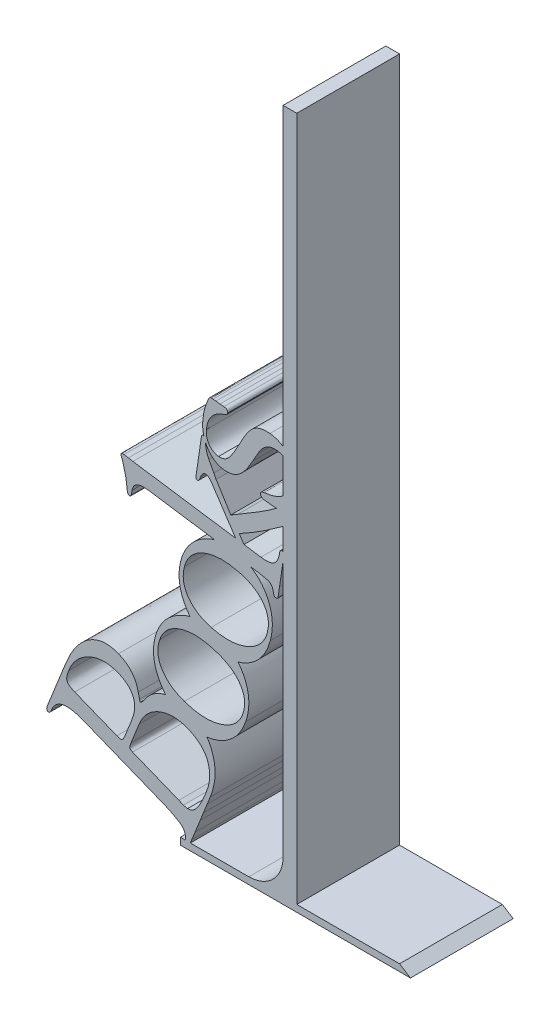
from build123d import *

# Parameters (mm, degrees)
BOSS_EXTRU_1_DEPTH = 30
BOSS_EXTRU_2_DEPTH = 30
CONG_1_R           = 10


with BuildPart() as part:
    # Esquisse1 → Boss.-Extru.1 (new body)
    with BuildSketch(Plane.XY):
        Polygon((0, 0), (37.189024069, 0), (34, 2), (4, 2), (4, 202), (0, 202), (0, 2), (-30, 2), (-30, 0), align=None)
    extrude(amount=BOSS_EXTRU_1_DEPTH)

    # Esquisse3 → Boss.-Extru.2 (add)
    with BuildSketch(Plane.XY):
        with BuildLine():
            Line((-35.302112501, 8.159006031), (-58.03965473, 17.252122586))
            add(Edge.make_bspline(
                [(-58.03965473, 17.252122586), (-58.355313773, 17.375350481), (-58.963035361, 17.612594602), (-59.859878294, 17.909773183), (-60.707648298, 18.138306557), (-61.506749373, 18.309469684), (-62.257632658, 18.432846565), (-62.964456405, 18.466854455), (-63.619206387, 18.451012021), (-64.229039011, 18.378327095), (-64.789443117, 18.233792106), (-65.314670395, 18.03619935), (-65.788879376, 17.757851222), (-66.220300759, 17.416496), (-66.629128968, 17.029218094), (-66.972831335, 16.555351762), (-67.295412383, 16.032333184), (-67.457774308, 15.6457702), (-67.541343919, 15.44680164)],
                knots=[0, 0, 0, 0, 0.001016459, 0.001956934, 0.002832792, 0.003649053, 0.004408297, 0.005112448, 0.00576834, 0.006371753, 0.006950187, 0.007500711, 0.008049922, 0.008591602, 0.009149295, 0.009732702, 0.010342145, 0.010988539, 0.010988539, 0.010988539, 0.010988539], degree=3))
            add(Edge.make_bspline(
                [(-67.541343919, 15.44680164), (-67.619917515, 15.265028843), (-67.75613238, 14.94990826), (-68.016939385, 14.588639119), (-68.325098744, 14.368209351), (-68.533711269, 14.416431409), (-68.634038176, 14.439622586)],
                knots=[0, 0, 0, 0, 0.000590712, 0.001024055, 0.001343459, 0.001639388, 0.001639388, 0.001639388, 0.001639388], degree=3))
            add(Edge.make_bspline(
                [(-68.634038176, 14.439622586), (-68.723149832, 14.491482144), (-68.908289689, 14.599226424), (-69.002186568, 14.957038171), (-68.955219486, 15.384166665), (-68.847878543, 15.68921238), (-68.786065203, 15.864875964)],
                knots=[0, 0, 0, 0, 0.000298359, 0.000619876, 0.001029442, 0.001585514, 0.001585514, 0.001585514, 0.001585514], degree=3))
            add(Edge.make_bspline(
                [(-68.786065203, 15.864875964), (-68.760613163, 15.925005499), (-68.692518061, 16.085877739), (-68.568086622, 16.392771783), (-68.399242924, 16.831966319), (-68.264070327, 17.166843433), (-68.187458784, 17.356641167)],
                knots=[0, 0, 0, 0, 0.000195882, 0.000524069, 0.000993418, 0.001607436, 0.001607436, 0.001607436, 0.001607436], degree=3))
            add(Edge.make_bspline(
                [(-68.187458784, 17.356641167), (-68.124265359, 17.518228579), (-67.986526828, 17.870429981), (-67.760475296, 18.438196242), (-67.490100792, 19.084427522), (-67.306262609, 19.544909176), (-67.208784798, 19.789073599)],
                knots=[0, 0, 0, 0, 0.000520516, 0.001134534, 0.001833279, 0.002621977, 0.002621977, 0.002621977, 0.002621977], degree=3))
            add(Edge.make_bspline(
                [(-67.208784798, 19.789073599), (-67.072882739, 20.131249445), (-66.817360969, 20.774605244), (-66.455736839, 21.672615505), (-66.15185427, 22.446745686), (-65.964214431, 22.918356439), (-65.878548311, 23.133668194)],
                knots=[0, 0, 0, 0, 0.001104528, 0.002076723, 0.002904243, 0.003599427, 0.003599427, 0.003599427, 0.003599427], degree=3))
            Line((-65.878548311, 23.133668194), (-64.557813514, 26.421252653))
            add(Edge.make_bspline(
                [(-64.557813514, 26.421252653), (-64.358699535, 26.925009982), (-63.971498429, 27.904626757), (-63.579515629, 28.882339884), (-63.389105744, 29.357274613)],
                knots=[0, 0, 0, 0, 0.001625039, 0.003160084, 0.003160084, 0.003160084, 0.003160084], degree=3))
            add(Edge.make_bspline(
                [(-63.389105744, 29.357274613), (-63.169378716, 29.878990693), (-62.741252187, 30.895526972), (-62.028419496, 32.346047181), (-61.264446433, 33.675917014), (-60.441002755, 34.877622829), (-59.585828991, 35.967872333), (-58.684009334, 36.945364246), (-57.721967137, 37.790435082), (-56.721217306, 38.518352039), (-55.690794802, 39.11682277), (-54.639763368, 39.579989604), (-53.573012969, 39.895018553), (-52.492016618, 40.084112375), (-51.392028033, 40.105988696), (-50.280501147, 39.997525603), (-49.149644692, 39.767640647), (-48.417659495, 39.493194928), (-48.043877703, 39.35305164)],
                knots=[0, 0, 0, 0, 0.00169804, 0.003308541, 0.004845379, 0.006294877, 0.007674946, 0.008999367, 0.010278465, 0.011510062, 0.012706294, 0.013846655, 0.014946965, 0.016035728, 0.017128794, 0.018235934, 0.019382021, 0.020577951, 0.020577951, 0.020577951, 0.020577951], degree=3))
            add(Edge.make_bspline(
                [(-48.043877703, 39.35305164), (-47.666245753, 39.186840964), (-46.929447075, 38.862546884), (-45.909438878, 38.25032833), (-45.015153381, 37.531646077), (-44.220025728, 36.731039995), (-43.565319734, 35.813141879), (-43.010001062, 34.814973298), (-42.576846349, 33.714468443), (-42.384625837, 32.938875825), (-42.285854055, 32.540340491)],
                knots=[0, 0, 0, 0, 0.001237009, 0.002413531, 0.003556147, 0.004671533, 0.005787163, 0.00692693, 0.008091459, 0.009322322, 0.009322322, 0.009322322, 0.009322322], degree=3))
            Line((-42.285854055, 32.540340491), (-41.896284798, 30.925053329))
            add(Edge.make_bspline(
                [(-41.896284798, 30.925053329), (-41.878934045, 30.771008605), (-41.852359302, 30.535070784), (-41.68041649, 30.380201451), (-41.620735811, 30.32644691)],
                knots=[0, 0, 0, 0, 0.000442518, 0.000677768, 0.000677768, 0.000677768, 0.000677768], degree=3))
            add(Edge.make_bspline(
                [(-41.620735811, 30.32644691), (-41.551563248, 30.340392893), (-41.363504833, 30.378307631), (-41.107817162, 30.675592142), (-40.755065825, 31.091008245), (-40.514510479, 31.456029721), (-40.376014528, 31.666185086)],
                knots=[0, 0, 0, 0, 0.00020752, 0.000564182, 0.001117731, 0.001868906, 0.001868906, 0.001868906, 0.001868906], degree=3))
            add(Edge.make_bspline(
                [(-40.376014528, 31.666185086), (-40.203849696, 31.914146666), (-39.862595765, 32.405639982), (-39.263951712, 33.06496259), (-38.640302078, 33.68092014), (-37.9581207, 34.222028113), (-37.235380288, 34.714050807), (-36.453003414, 35.124879102), (-35.63389224, 35.492566677), (-34.770383596, 35.782245849), (-33.88471145, 36.010300137), (-32.99157699, 36.162220932), (-32.10165262, 36.240058743), (-31.214937057, 36.238636955), (-30.326604735, 36.166750555), (-29.442944458, 35.995665553), (-28.554461563, 35.778161822), (-27.980664066, 35.558598107), (-27.69125946, 35.447857383)],
                knots=[0, 0, 0, 0, 0.000904659, 0.001793155, 0.002666691, 0.003531814, 0.004401466, 0.005285684, 0.006179045, 0.007092493, 0.008014304, 0.008920309, 0.009807229, 0.010690887, 0.011577807, 0.012476106, 0.013388714, 0.014317403, 0.014317403, 0.014317403, 0.014317403], degree=3))
            add(Edge.make_bspline(
                [(-27.69125946, 35.447857383), (-27.265753786, 35.263404732), (-26.432274912, 34.902099591), (-25.272392763, 34.218936166), (-24.223954607, 33.435580334), (-23.26953076, 32.559703627), (-22.444950765, 31.561451076), (-21.716105466, 30.470897878), (-21.097465064, 29.279335813), (-20.600921226, 27.996516562), (-20.206775025, 26.656863977), (-19.966413692, 25.273077575), (-19.838716302, 23.868225734), (-19.847625921, 22.439163094), (-20.004316595, 20.985994781), (-20.296902681, 19.510988717), (-20.696421705, 18.002929073), (-21.075117354, 17.014657935), (-21.268117568, 16.510990829)],
                knots=[0, 0, 0, 0, 0.001390302, 0.002723318, 0.004026956, 0.00531109, 0.006599437, 0.007901272, 0.009239966, 0.010618005, 0.01202236, 0.013422079, 0.014824278, 0.016249563, 0.017701799, 0.019201893, 0.020757764, 0.022374839, 0.022374839, 0.022374839, 0.022374839], degree=3))
            Line((-21.268117568, 16.510990829), (-22.170778041, 14.240087113))
            Line((-22.170778041, 14.240087113), (-23.263472298, 11.503600626))
            Line((-23.263472298, 11.503600626), (-24.213641217, 9.128178329))
            add(Edge.make_bspline(
                [(-24.213641217, 9.128178329), (-24.361571263, 8.754073749), (-24.640130174, 8.049618053), (-25.047724429, 7.059767976), (-25.382308567, 6.183283802), (-25.603129942, 5.643857322), (-25.705406419, 5.394014477)],
                knots=[0, 0, 0, 0, 0.001206864, 0.002272579, 0.003211277, 0.004021153, 0.004021153, 0.004021153, 0.004021153], degree=3))
            add(Edge.make_bspline(
                [(-25.705406419, 5.394014477), (-25.87572996, 4.966153219), (-26.188971304, 4.179275285), (-26.50938508, 3.395291682), (-26.655575338, 3.037595558)],
                knots=[0, 0, 0, 0, 0.00138154, 0.002540785, 0.002540785, 0.002540785, 0.002540785], degree=3))
            add(Edge.make_bspline(
                [(-26.655575338, 3.037595558), (-26.740201249, 2.818702199), (-26.895028946, 2.418224918), (-27.121148607, 1.870154371), (-27.294048616, 1.420492239), (-27.405677567, 1.156045727), (-27.45371723, 1.042240829)],
                knots=[0, 0, 0, 0, 0.000704023, 0.001288049, 0.00177856, 0.002149126, 0.002149126, 0.002149126, 0.002149126], degree=3))
            add(Edge.make_bspline(
                [(-27.45371723, 1.042240829), (-27.507364885, 0.924746659), (-27.603880451, 0.713367125), (-27.823201528, 0.469730152), (-28.11516529, 0.376212114), (-28.296807436, 0.432435134), (-28.39438446, 0.462637788)],
                knots=[0, 0, 0, 0, 0.000386778, 0.000695839, 0.000954313, 0.001254332, 0.001254332, 0.001254332, 0.001254332], degree=3))
            add(Edge.make_bspline(
                [(-28.39438446, 0.462637788), (-28.467866027, 0.50356667), (-28.616519866, 0.586366149), (-28.720753854, 0.856663082), (-28.728652929, 1.190573434), (-28.679045201, 1.435515017), (-28.650930068, 1.574335423)],
                knots=[0, 0, 0, 0, 0.00024521, 0.000496062, 0.000819678, 0.00124301, 0.00124301, 0.00124301, 0.00124301], degree=3))
            add(Edge.make_bspline(
                [(-28.650930068, 1.574335423), (-28.607401578, 1.785657401), (-28.523538759, 2.192794356), (-28.49102629, 2.798668844), (-28.560368307, 3.369166081), (-28.70927724, 3.904079452), (-28.955410011, 4.401962582), (-29.28917227, 4.86186631), (-29.728172918, 5.27280665), (-30.063581904, 5.508957239), (-30.237712163, 5.631556707)],
                knots=[0, 0, 0, 0, 0.000646743, 0.001246028, 0.00181056, 0.002363946, 0.002903622, 0.003468074, 0.004059473, 0.004697998, 0.004697998, 0.004697998, 0.004697998], degree=3))
            add(Edge.make_bspline(
                [(-30.237712163, 5.631556707), (-30.583806243, 5.847678046), (-31.310995358, 6.301777361), (-32.504529353, 6.935388369), (-33.848046102, 7.561448849), (-34.803139698, 7.953950209), (-35.302112501, 8.159006031)],
                knots=[0, 0, 0, 0, 0.001223801, 0.002571367, 0.004050613, 0.005668832, 0.005668832, 0.005668832, 0.005668832], degree=3))
        make_face()
        with BuildLine():
            Line((-46.08652973, 19.694056707), (-44.186191892, 24.46390468))
            add(Edge.make_bspline(
                [(-44.186191892, 24.46390468), (-44.074721727, 24.760299336), (-43.859855049, 25.331621134), (-43.607548383, 26.187951087), (-43.437838458, 27.008059297), (-43.338011243, 27.796234646), (-43.319121678, 28.547173716), (-43.369504847, 29.266044629), (-43.520987168, 29.945201824), (-43.72158397, 30.59851231), (-44.027453098, 31.207172772), (-44.384515049, 31.795526321), (-44.838153609, 32.336327745), (-45.363534479, 32.84305256), (-45.96950405, 33.308256836), (-46.644783221, 33.746099555), (-47.398251889, 34.146912862), (-47.937362645, 34.37220281), (-48.214908109, 34.488186775)],
                knots=[0, 0, 0, 0, 0.000949789, 0.001830785, 0.00267494, 0.003459851, 0.004210725, 0.004925628, 0.005615139, 0.006294228, 0.006969917, 0.007652784, 0.008354752, 0.009080497, 0.009838849, 0.010642683, 0.011492805, 0.012394865, 0.012394865, 0.012394865, 0.012394865], degree=3))
            add(Edge.make_bspline(
                [(-48.214908109, 34.488186775), (-48.567259133, 34.619193315), (-49.261897009, 34.877464468), (-50.330337719, 35.130390391), (-51.39317254, 35.276847634), (-52.454384403, 35.306042355), (-53.510750766, 35.216548571), (-54.566888728, 35.029615034), (-55.613187603, 34.710873197), (-56.642017048, 34.283615555), (-57.636252595, 33.765267104), (-58.567989569, 33.156511669), (-59.427432723, 32.469616665), (-60.216560502, 31.701998545), (-60.926170434, 30.846010762), (-61.564464841, 29.91040188), (-62.131360198, 28.895935837), (-62.442048422, 28.175727169), (-62.600465541, 27.808499275)],
                knots=[0, 0, 0, 0, 0.001126862, 0.002221537, 0.003285811, 0.004340884, 0.005399033, 0.006461354, 0.00755256, 0.008673034, 0.009799295, 0.010911439, 0.012006568, 0.013095082, 0.01420824, 0.015336223, 0.016488908, 0.017688117, 0.017688117, 0.017688117, 0.017688117], degree=3))
            add(Edge.make_bspline(
                [(-62.600465541, 27.808499275), (-62.7156248, 27.50043675), (-62.925312334, 26.939501647), (-63.109527137, 26.144585285), (-63.181187993, 25.484877529), (-63.082277344, 24.92262247), (-62.773817218, 24.451957203), (-62.287947379, 24.040006067), (-61.616910769, 23.641589613), (-61.09301385, 23.418172151), (-60.804646284, 23.29519691)],
                knots=[0, 0, 0, 0, 0.000985614, 0.001794654, 0.002442513, 0.002966141, 0.003469731, 0.004095473, 0.004862996, 0.005802703, 0.005802703, 0.005802703, 0.005802703], degree=3))
            Line((-60.804646284, 23.29519691), (-48.499958784, 18.37332191))
            add(Edge.make_bspline(
                [(-48.499958784, 18.37332191), (-48.336482077, 18.312986371), (-48.038955366, 18.203176021), (-47.624145983, 18.1003381), (-47.287944665, 18.082734748), (-46.999145372, 18.144668154), (-46.775836505, 18.368955121), (-46.548732279, 18.687558707), (-46.32176643, 19.149220841), (-46.170205247, 19.500254368), (-46.08652973, 19.694056707)],
                knots=[0, 0, 0, 0, 0.000522852, 0.000951588, 0.001274785, 0.001530626, 0.001806829, 0.00219454, 0.002708774, 0.003342615, 0.003342615, 0.003342615, 0.003342615], degree=3))
        make_face(mode=Mode.SUBTRACT)
        with BuildLine():
            add(Edge.make_bspline(
                [(-44.385727365, 18.648870896), (-44.453678344, 18.485652257), (-44.576078147, 18.19164723), (-44.679711168, 17.779600312), (-44.765451733, 17.465471787), (-44.762296774, 17.213044883), (-44.677882888, 17.005318803), (-44.494776099, 16.843127027), (-44.248484023, 16.683341967), (-44.048581726, 16.59652457), (-43.939147974, 16.548997586)],
                knots=[0, 0, 0, 0, 0.000529373, 0.000953557, 0.001274089, 0.001502328, 0.00169821, 0.001926646, 0.002221811, 0.002578852, 0.002578852, 0.002578852, 0.002578852], degree=3))
            Line((-43.939147974, 16.548997586), (-30.418244257, 11.142536437))
            Line((-30.418244257, 11.142536437), (-29.09750946, 10.543930018))
            Line((-29.09750946, 10.543930018), (-27.881293244, 10.277882721))
            add(Edge.make_bspline(
                [(-27.881293244, 10.277882721), (-27.644083423, 10.281839645), (-27.163021767, 10.289864289), (-26.467907739, 10.591656717), (-25.79766613, 11.057543304), (-25.163204681, 11.758943031), (-24.525465815, 12.682456471), (-23.868148397, 13.856062501), (-23.185486694, 15.294230022), (-22.748392778, 16.350389448), (-22.512838852, 16.919563464)],
                knots=[0, 0, 0, 0, 0.000705432, 0.001430617, 0.002229268, 0.003143408, 0.004247976, 0.005592692, 0.007173632, 0.009021386, 0.009021386, 0.009021386, 0.009021386], degree=3))
            add(Edge.make_bspline(
                [(-22.512838852, 16.919563464), (-22.368016386, 17.304095456), (-22.08499336, 18.05557698), (-21.763441588, 19.183132479), (-21.538927387, 20.275360058), (-21.422258329, 21.331701702), (-21.414605082, 22.356204778), (-21.494311668, 23.344232539), (-21.687823017, 24.297057692), (-21.981714929, 25.208452101), (-22.373559285, 26.073380396), (-22.848317416, 26.89278835), (-23.435120186, 27.64144354), (-24.103897269, 28.341888886), (-24.86621338, 28.978348844), (-25.725546186, 29.552110635), (-26.672529698, 30.074920077), (-27.352795548, 30.367051394), (-27.700761149, 30.516480694)],
                knots=[0, 0, 0, 0, 0.001232293, 0.002408239, 0.003513258, 0.00457409, 0.005590816, 0.006582685, 0.007542355, 0.008500896, 0.009449258, 0.010386271, 0.011334633, 0.01229562, 0.013287125, 0.014306997, 0.015391398, 0.016526919, 0.016526919, 0.016526919, 0.016526919], degree=3))
            add(Edge.make_bspline(
                [(-27.700761149, 30.516480694), (-28.06597229, 30.65293199), (-28.786848191, 30.922267835), (-29.888034936, 31.20588688), (-30.976368869, 31.376916338), (-32.052021312, 31.449181938), (-33.115247274, 31.397658109), (-34.170262123, 31.248393276), (-35.209213129, 30.9759614), (-36.228881151, 30.610834367), (-37.202209186, 30.143075928), (-38.124605827, 29.606156758), (-38.958844486, 28.96279075), (-39.728237346, 28.24835251), (-40.410452445, 27.441769124), (-41.037197262, 26.563747679), (-41.576102259, 25.590893885), (-41.876560756, 24.900436159), (-42.029308446, 24.549419883)],
                knots=[0, 0, 0, 0, 0.001169017, 0.002307476, 0.003404088, 0.004470354, 0.005535603, 0.006591787, 0.007661097, 0.008752137, 0.009835913, 0.010896746, 0.01194766, 0.012989602, 0.014040817, 0.015111139, 0.016221374, 0.017369467, 0.017369467, 0.017369467, 0.017369467], degree=3))
            Line((-42.029308446, 24.549419883), (-44.385727365, 18.648870896))
        make_face(mode=Mode.SUBTRACT)
        with BuildLine():
            add(Edge.make_bspline(
                [(-36.972241579, 50.116979393), (-36.807837935, 50.561482078), (-36.483566384, 51.438224052), (-35.832902584, 52.665210126), (-35.104203056, 53.810374036), (-34.271076676, 54.868403768), (-33.324576665, 55.825492512), (-32.286342593, 56.70700323), (-31.138998894, 57.488615003), (-29.90006691, 58.162704485), (-28.616235713, 58.739969798), (-27.308803719, 59.182796405), (-25.995628038, 59.473787111), (-24.686007191, 59.656082531), (-23.36644031, 59.66691795), (-22.048057801, 59.556868894), (-20.723388163, 59.297886464), (-19.860545961, 59.025357194), (-19.422621646, 58.887038515)],
                knots=[0, 0, 0, 0, 0.001420367, 0.002801548, 0.004156297, 0.005488873, 0.006832682, 0.008187964, 0.009568949, 0.010989285, 0.012414221, 0.013787372, 0.015122012, 0.016444352, 0.017746223, 0.01907187, 0.020407964, 0.021784955, 0.021784955, 0.021784955, 0.021784955], degree=3))
            add(Edge.make_bspline(
                [(-19.422621646, 58.887038515), (-18.956253974, 58.712476012), (-18.043801086, 58.370942777), (-16.763483387, 57.71169898), (-15.576605507, 56.978106515), (-14.508375531, 56.120130089), (-13.530668787, 55.178468236), (-12.663345855, 54.129994026), (-11.912232687, 52.977653048), (-11.25705769, 51.749636784), (-10.728252356, 50.457057215), (-10.33822074, 49.128595417), (-10.076237778, 47.780123801), (-9.962937628, 46.403924223), (-9.994898913, 45.006852586), (-10.15825188, 43.588140225), (-10.461079405, 42.14590027), (-10.770258047, 41.195527177), (-10.928111511, 40.710307096)],
                knots=[0, 0, 0, 0, 0.001492703, 0.002920488, 0.004312412, 0.005671685, 0.007022296, 0.008378777, 0.009743882, 0.01114231, 0.012548592, 0.013925583, 0.015289663, 0.016662649, 0.018059688, 0.019475185, 0.020941804, 0.022471694, 0.022471694, 0.022471694, 0.022471694], degree=3))
            add(Edge.make_bspline(
                [(-10.928111511, 40.710307096), (-11.103855457, 40.24452517), (-11.448198253, 39.331898283), (-12.092101346, 38.041249178), (-12.819402005, 36.851901138), (-13.645971644, 35.768432656), (-14.555526768, 34.78306416), (-15.574641609, 33.918533259), (-16.67042881, 33.140835757), (-17.853623312, 32.481981171), (-19.090522347, 31.940579977), (-20.365243776, 31.538702726), (-21.661194952, 31.272481557), (-22.982251331, 31.13630582), (-24.326888664, 31.146641891), (-25.693613674, 31.306713323), (-27.086754691, 31.584740053), (-28.002073022, 31.883242452), (-28.468229755, 32.035264866)],
                knots=[0, 0, 0, 0, 0.001492703, 0.002924718, 0.004319688, 0.005668961, 0.007006811, 0.008334228, 0.009670761, 0.011032026, 0.012389471, 0.01371471, 0.015034042, 0.016352006, 0.017691778, 0.019058998, 0.020475228, 0.021945044, 0.021945044, 0.021945044, 0.021945044], degree=3))
            add(Edge.make_bspline(
                [(-28.468229755, 32.035264866), (-28.915499266, 32.203727403), (-29.796586713, 32.535585987), (-31.035670971, 33.180923036), (-32.18364161, 33.918941537), (-33.22519341, 34.779983333), (-34.193953883, 35.725149935), (-35.045032029, 36.799096537), (-35.811765682, 37.964402482), (-36.470359033, 39.222732584), (-37.016673227, 40.535378049), (-37.429298187, 41.878383073), (-37.708131286, 43.230156256), (-37.842048878, 44.593295482), (-37.829888916, 45.965428034), (-37.684244043, 47.345315623), (-37.414581547, 48.741818542), (-37.121173742, 49.653974249), (-36.972241579, 50.116979393)],
                knots=[0, 0, 0, 0, 0.001432709, 0.002822329, 0.004182232, 0.005519306, 0.006869783, 0.008234988, 0.009621193, 0.011049262, 0.012489137, 0.013880704, 0.015257794, 0.016623031, 0.017981806, 0.019366904, 0.020781252, 0.022239227, 0.022239227, 0.022239227, 0.022239227], degree=3))
        make_face()
        with BuildLine():
            add(Edge.make_bspline(
                [(-36.02207266, 48.919766555), (-36.119672388, 48.607818121), (-36.311716389, 47.994006721), (-36.496368455, 47.06160567), (-36.558837536, 46.143050212), (-36.534515187, 45.241084693), (-36.400099423, 44.35427232), (-36.161043928, 43.483532975), (-35.812849096, 42.631065502), (-35.368774917, 41.798911981), (-34.828060409, 41.004534878), (-34.204274817, 40.260036352), (-33.509880166, 39.560743173), (-32.726521148, 38.925650439), (-31.863752073, 38.342989465), (-30.923391201, 37.812354018), (-29.902291249, 37.336021989), (-29.185947502, 37.066433502), (-28.819792255, 36.928634799)],
                knots=[0, 0, 0, 0, 0.000980195, 0.0019287, 0.002843283, 0.003736897, 0.004630511, 0.0055272, 0.006439412, 0.007387345, 0.008351895, 0.009316633, 0.010297564, 0.011303712, 0.012336778, 0.013417509, 0.014539714, 0.015713086, 0.015713086, 0.015713086, 0.015713086], degree=3))
            add(Edge.make_bspline(
                [(-28.819792255, 36.928634799), (-28.343326169, 36.773847329), (-27.407958939, 36.469978637), (-25.999861994, 36.123357261), (-24.616405009, 35.907078133), (-23.263887121, 35.792106164), (-21.93790634, 35.774173944), (-20.638631463, 35.896565354), (-19.365086464, 36.108233366), (-18.136469462, 36.44379267), (-16.968608584, 36.863668993), (-15.89726378, 37.386382878), (-14.922890667, 37.986458827), (-14.062833592, 38.681839263), (-13.315778243, 39.472702575), (-12.664143425, 40.338446817), (-12.124933665, 41.298036519), (-11.860402465, 41.986143258), (-11.726253403, 42.335095947)],
                knots=[0, 0, 0, 0, 0.001502649, 0.002949904, 0.004344873, 0.005698922, 0.007019691, 0.008316942, 0.009608787, 0.010887991, 0.012132458, 0.013326575, 0.014457636, 0.015558725, 0.016634055, 0.017713448, 0.018802459, 0.019922934, 0.019922934, 0.019922934, 0.019922934], degree=3))
            add(Edge.make_bspline(
                [(-11.726253403, 42.335095947), (-11.627297581, 42.643658282), (-11.433770033, 43.247112541), (-11.268921482, 44.166239719), (-11.181902739, 45.063899183), (-11.227228374, 45.940884826), (-11.355185803, 46.801061052), (-11.607836247, 47.634656104), (-11.954435488, 48.453577663), (-12.399398685, 49.247790585), (-12.942906638, 50.007418855), (-13.573192415, 50.723883389), (-14.293798512, 51.389296433), (-15.089034216, 52.020668227), (-15.982166114, 52.58377577), (-16.94257309, 53.125693095), (-18.003457498, 53.594958727), (-18.746495366, 53.87094441), (-19.128069282, 54.012671961)],
                knots=[0, 0, 0, 0, 0.00097108, 0.001899138, 0.002795525, 0.003670507, 0.004526556, 0.005398436, 0.00627553, 0.007190114, 0.008123458, 0.009072724, 0.010047516, 0.011062552, 0.012114154, 0.013211465, 0.014368215, 0.015589321, 0.015589321, 0.015589321, 0.015589321], degree=3))
            add(Edge.make_bspline(
                [(-19.128069282, 54.012671961), (-19.616904921, 54.174928026), (-20.573244713, 54.492359734), (-22.010630555, 54.838916638), (-23.406199183, 55.090366774), (-24.761985102, 55.240382332), (-26.084761054, 55.255054574), (-27.365399197, 55.171935976), (-28.610331752, 54.984685714), (-29.801056171, 54.677922106), (-30.928736938, 54.288463909), (-31.959807236, 53.791288816), (-32.894261689, 53.209271528), (-33.723620964, 52.52880207), (-34.465307892, 51.766165191), (-35.092335118, 50.90311882), (-35.624798462, 49.952891694), (-35.887875772, 49.268750152), (-36.02207266, 48.919766555)],
                knots=[0, 0, 0, 0, 0.001544602, 0.003021801, 0.004430873, 0.005797069, 0.00710844, 0.008394016, 0.009643768, 0.010878987, 0.012078046, 0.013216981, 0.014305744, 0.015372729, 0.016427759, 0.017488209, 0.018564293, 0.019684768, 0.019684768, 0.019684768, 0.019684768], degree=3))
        make_face(mode=Mode.SUBTRACT)
        with BuildLine():
            add(Edge.make_bspline(
                [(-29.808187507, 72.110221896), (-29.674028994, 72.565940591), (-29.409902334, 73.463143866), (-28.874233897, 74.744579323), (-28.220805323, 75.934706703), (-27.479423144, 77.05784693), (-26.623617666, 78.090627616), (-25.662781852, 79.042719476), (-24.592968496, 79.906029466), (-23.437349976, 80.687702827), (-22.218925518, 81.358014847), (-20.973951965, 81.905119179), (-19.711698473, 82.304272697), (-18.43950964, 82.577833362), (-17.151518013, 82.697259255), (-15.852445065, 82.689977301), (-14.542678166, 82.538644294), (-13.682104489, 82.333368961), (-13.24674325, 82.229520882)],
                knots=[0, 0, 0, 0, 0.00142443, 0.002804368, 0.004156449, 0.005492543, 0.006835646, 0.008172686, 0.009543863, 0.010953767, 0.012352873, 0.013710318, 0.015026499, 0.016317925, 0.017606587, 0.018898852, 0.020209431, 0.02155129, 0.02155129, 0.02155129, 0.02155129], degree=3))
            add(Edge.make_bspline(
                [(-13.24674325, 82.229520882), (-12.781424671, 82.092460293), (-11.867850806, 81.823365143), (-10.567208637, 81.278109406), (-9.368549304, 80.617988084), (-8.253834722, 79.866565509), (-7.24406109, 78.998499677), (-6.333214236, 78.017339259), (-5.518284804, 76.932756078), (-4.797403627, 75.756690787), (-4.191040316, 74.513851667), (-3.728079305, 73.221099101), (-3.376103815, 71.903777745), (-3.18098037, 70.545603449), (-3.114146764, 69.151977549), (-3.184405499, 67.72423676), (-3.380517102, 66.263608505), (-3.6158487, 65.295739001), (-3.735552371, 64.803422909)],
                knots=[0, 0, 0, 0, 0.001454472, 0.002855609, 0.004220582, 0.005554106, 0.006881523, 0.008205944, 0.009562791, 0.010944691, 0.01233856, 0.013703169, 0.015058284, 0.016422199, 0.017811039, 0.019237843, 0.020705232, 0.022224343, 0.022224343, 0.022224343, 0.022224343], degree=3))
            add(Edge.make_bspline(
                [(-3.735552371, 64.803422909), (-3.877074306, 64.325908739), (-4.154350418, 63.390341593), (-4.687928128, 62.051764871), (-5.323568922, 60.813364804), (-6.063506185, 59.674357108), (-6.886945231, 58.624330389), (-7.820796598, 57.675928587), (-8.844696945, 56.82161201), (-9.956867735, 56.072196014), (-11.130266836, 55.437080371), (-12.348252771, 54.928011118), (-13.603162533, 54.570581537), (-14.880794839, 54.325987424), (-16.194523622, 54.231014847), (-17.536386618, 54.28829579), (-18.916468449, 54.45015711), (-19.830135555, 54.674174971), (-20.296996628, 54.788642504)],
                knots=[0, 0, 0, 0, 0.00149358, 0.002926288, 0.004315908, 0.00566267, 0.006995246, 0.008312181, 0.009647972, 0.01098936, 0.012328559, 0.013644911, 0.014940943, 0.016236139, 0.017541333, 0.018881914, 0.020260805, 0.021701588, 0.021701588, 0.021701588, 0.021701588], degree=3))
            add(Edge.make_bspline(
                [(-20.296996628, 54.788642504), (-20.743180778, 54.923103102), (-21.624423405, 55.1886715), (-22.881408483, 55.72171416), (-24.050499913, 56.371724163), (-25.130372662, 57.139915793), (-26.134048608, 58.012155581), (-27.03531777, 59.013555462), (-27.871217656, 60.10588804), (-28.589386664, 61.310402505), (-29.220618105, 62.56964005), (-29.699567316, 63.879546473), (-30.070388679, 65.202450835), (-30.285810268, 66.550778859), (-30.372757073, 67.915913915), (-30.322131066, 69.299669096), (-30.144403507, 70.706695433), (-29.921579648, 71.636868842), (-29.808187507, 72.110221896)],
                knots=[0, 0, 0, 0, 0.001397265, 0.00275969, 0.0040868, 0.00540233, 0.006728794, 0.008067184, 0.009437339, 0.010848524, 0.012267811, 0.013656813, 0.015026013, 0.016383458, 0.017744888, 0.019123452, 0.020531819, 0.021991156, 0.021991156, 0.021991156, 0.021991156], degree=3))
        make_face()
        with BuildLine():
            add(Edge.make_bspline(
                [(-28.801008452, 70.989022572), (-28.877135215, 70.667147671), (-29.026017454, 70.037652147), (-29.136524417, 69.08885708), (-29.166019495, 68.161189902), (-29.059554149, 67.258188784), (-28.889832067, 66.373721607), (-28.583326918, 65.523831501), (-28.195149151, 64.694708221), (-27.708084701, 63.894995726), (-27.133071459, 63.138839768), (-26.47072313, 62.445136574), (-25.744243702, 61.799674488), (-24.936390653, 61.224203634), (-24.054712349, 60.70758627), (-23.102397759, 60.255832441), (-22.080398142, 59.846943149), (-21.360200788, 59.643755901), (-20.990619939, 59.539487099)],
                knots=[0, 0, 0, 0, 0.000991459, 0.001939012, 0.002860871, 0.003768519, 0.004661122, 0.005556602, 0.006470445, 0.007404177, 0.008360077, 0.009314512, 0.010277188, 0.011271285, 0.012284897, 0.013338857, 0.014431055, 0.015582329, 0.015582329, 0.015582329, 0.015582329], degree=3))
            add(Edge.make_bspline(
                [(-20.990619939, 59.539487099), (-20.51714232, 59.420995472), (-19.586296954, 59.188043845), (-18.183746668, 58.974767038), (-16.81869074, 58.858381247), (-15.487127519, 58.84491533), (-14.189441935, 58.948969841), (-12.924900062, 59.169898892), (-11.69231091, 59.490627329), (-10.510601997, 59.927992038), (-9.401151392, 60.453396343), (-8.380915042, 61.053347228), (-7.470424641, 61.737305102), (-6.682442236, 62.515068934), (-5.983962769, 63.354050809), (-5.417490199, 64.286524605), (-4.940316869, 65.286929427), (-4.727163075, 66.000371127), (-4.619209466, 66.361699936)],
                knots=[0, 0, 0, 0, 0.001463538, 0.002877279, 0.004250265, 0.005571034, 0.006867484, 0.008149965, 0.009417542, 0.010683123, 0.011924176, 0.013095815, 0.014228431, 0.015330381, 0.016410736, 0.017494471, 0.018595437, 0.01972522, 0.01972522, 0.01972522, 0.01972522], degree=3))
            add(Edge.make_bspline(
                [(-4.619209466, 66.361699936), (-4.543429627, 66.680396121), (-4.395268855, 67.303494206), (-4.280310553, 68.239633967), (-4.267878391, 69.148260051), (-4.365126133, 70.027933055), (-4.555835008, 70.878985867), (-4.841541102, 71.703592101), (-5.235160441, 72.497729626), (-5.732731189, 73.254527672), (-6.309531799, 73.975888219), (-6.972836011, 74.646471996), (-7.714481461, 75.263373177), (-8.536020286, 75.824649179), (-9.434892741, 76.331938905), (-10.420243191, 76.77446258), (-11.481852407, 77.177074403), (-12.228279422, 77.389175056), (-12.610130074, 77.497679666)],
                knots=[0, 0, 0, 0, 0.000982173, 0.001920294, 0.002823004, 0.003702308, 0.004569048, 0.005434484, 0.006314096, 0.007220699, 0.008146663, 0.009080588, 0.010045325, 0.011036283, 0.012061629, 0.013137379, 0.014273933, 0.01546434, 0.01546434, 0.01546434, 0.01546434], degree=3))
            add(Edge.make_bspline(
                [(-12.610130074, 77.497679666), (-13.099892538, 77.616593134), (-14.055181715, 77.84853567), (-15.477965358, 78.107225926), (-16.861252617, 78.221238661), (-18.198497383, 78.261962382), (-19.490810488, 78.166815977), (-20.741163385, 77.999588882), (-21.939348424, 77.684393034), (-23.087080408, 77.293081805), (-24.160025824, 76.799657266), (-25.140157333, 76.223467062), (-26.019498322, 75.55962864), (-26.790395384, 74.810451875), (-27.449719667, 73.971833292), (-28.019361128, 73.061703478), (-28.477044514, 72.060876968), (-28.691965215, 71.349798755), (-28.801008452, 70.989022572)],
                knots=[0, 0, 0, 0, 0.001511963, 0.002949108, 0.004332379, 0.00567242, 0.006957995, 0.008215741, 0.00945096, 0.010667956, 0.011849876, 0.012987304, 0.014072411, 0.015147489, 0.016202561, 0.017265137, 0.01836212, 0.019491902, 0.019491902, 0.019491902, 0.019491902], degree=3))
        make_face(mode=Mode.SUBTRACT)
        with BuildLine():
            Line((-13.833393127, 85.645027523), (-20.788629613, 96.068380563))
            add(Edge.make_bspline(
                [(-20.788629613, 96.068380563), (-20.927261436, 96.261726777), (-21.179672747, 96.613758296), (-21.576139717, 97.048295571), (-21.95453352, 97.352491148), (-22.226539844, 97.430575431), (-22.34690664, 97.465128874)],
                knots=[0, 0, 0, 0, 0.000712627, 0.001297502, 0.001766947, 0.002139578, 0.002139578, 0.002139578, 0.002139578], degree=3))
            add(Edge.make_bspline(
                [(-22.34690664, 97.465128874), (-22.534479334, 97.474056399), (-22.907133533, 97.49179288), (-23.427218453, 97.172718192), (-23.839074966, 96.634243275), (-24.021861107, 96.179352599), (-24.123722518, 95.925855225)],
                knots=[0, 0, 0, 0, 0.000551835, 0.00109634, 0.001744826, 0.002561087, 0.002561087, 0.002561087, 0.002561087], degree=3))
            add(Edge.make_bspline(
                [(-24.123722518, 95.925855225), (-24.186459536, 95.740916724), (-24.295687866, 95.418929412), (-24.519615225, 95.052663035), (-24.718181803, 94.776058161), (-24.895725692, 94.755976048), (-24.969372856, 94.747645766)],
                knots=[0, 0, 0, 0, 0.000580537, 0.001010744, 0.001313161, 0.001527529, 0.001527529, 0.001527529, 0.001527529], degree=3))
            add(Edge.make_bspline(
                [(-24.969372856, 94.747645766), (-25.056028719, 94.767460349), (-25.222982944, 94.80563582), (-25.408437045, 95.015978902), (-25.449763051, 95.318138375), (-25.422047966, 95.530688153), (-25.406450559, 95.650306239)],
                knots=[0, 0, 0, 0, 0.000261426, 0.000503672, 0.000785057, 0.001147245, 0.001147245, 0.001147245, 0.001147245], degree=3))
            add(Edge.make_bspline(
                [(-25.406450559, 95.650306239), (-25.390426498, 95.748460414), (-25.353761674, 95.973048034), (-25.296357873, 96.356254046), (-25.232491429, 96.832175209), (-25.179065291, 97.180172667), (-25.149904951, 97.370111982)],
                knots=[0, 0, 0, 0, 0.000298359, 0.000682679, 0.001162396, 0.001738876, 0.001738876, 0.001738876, 0.001738876], degree=3))
            add(Edge.make_bspline(
                [(-25.149904951, 97.370111982), (-25.125124106, 97.544392516), (-25.068308893, 97.943966687), (-24.957498609, 98.616724775), (-24.851491066, 99.445454967), (-24.761588036, 100.046601421), (-24.712827248, 100.372645766)],
                knots=[0, 0, 0, 0, 0.000528092, 0.001210761, 0.002045234, 0.003034232, 0.003034232, 0.003034232, 0.003034232], degree=3))
            add(Edge.make_bspline(
                [(-24.712827248, 100.372645766), (-24.642504958, 100.83813335), (-24.513369841, 101.692923402), (-24.345311969, 102.865707137), (-24.200128115, 103.811848138), (-24.120210679, 104.369638856), (-24.085715762, 104.610399144)],
                knots=[0, 0, 0, 0, 0.001412304, 0.00259346, 0.003554259, 0.004283912, 0.004283912, 0.004283912, 0.004283912], degree=3))
            add(Edge.make_bspline(
                [(-24.085715762, 104.610399144), (-24.056295577, 104.793963962), (-24.001568681, 105.135427915), (-23.939586577, 105.605304251), (-23.88085125, 105.9914671), (-23.845077748, 106.219363353), (-23.829170154, 106.320703198)],
                knots=[0, 0, 0, 0, 0.000557693, 0.001037411, 0.001421731, 0.001729474, 0.001729474, 0.001729474, 0.001729474], degree=3))
            add(Edge.make_bspline(
                [(-23.829170154, 106.320703198), (-23.811946565, 106.413819977), (-23.780759082, 106.582430485), (-23.67221077, 106.794701573), (-23.499266531, 106.918765532), (-23.371673142, 106.925417559), (-23.306577248, 106.928811306)],
                knots=[0, 0, 0, 0, 0.000283463, 0.000513278, 0.000697767, 0.000889927, 0.000889927, 0.000889927, 0.000889927], degree=3))
            add(Edge.make_bspline(
                [(-23.306577248, 106.928811306), (-23.224713798, 106.905064622), (-23.036308692, 106.850412678), (-22.867674702, 106.531355277), (-22.751733957, 106.105561182), (-22.717868146, 105.765095331), (-22.69846914, 105.570069752)],
                knots=[0, 0, 0, 0, 0.000247044, 0.000568561, 0.001004501, 0.001589067, 0.001589067, 0.001589067, 0.001589067], degree=3))
            add(Edge.make_bspline(
                [(-22.69846914, 105.570069752), (-22.65788183, 105.182621914), (-22.580510575, 104.444033294), (-22.363130853, 103.409671106), (-22.077565206, 102.498416266), (-21.802979568, 101.965861028), (-21.672286708, 101.712383942)],
                knots=[0, 0, 0, 0, 0.001167935, 0.002226425, 0.0031669, 0.004021101, 0.004021101, 0.004021101, 0.004021101], degree=3))
            Line((-21.672286708, 101.712383942), (-20.218528262, 98.966395766))
            Line((-20.218528262, 98.966395766), (-19.543908329, 97.664664347))
            Line((-19.543908329, 97.664664347), (-15.268148194, 90.823448131))
            Line((-15.268148194, 90.823448131), (-13.20628164, 92.030162658))
            add(Edge.make_bspline(
                [(-13.20628164, 92.030162658), (-12.451825049, 92.472464377), (-11.016039606, 93.314196527), (-8.978415526, 94.531924357), (-7.16811156, 95.63782381), (-5.588290294, 96.63685626), (-4.237195848, 97.518217247), (-3.114603357, 98.286477675), (-2.214492116, 98.937573621), (-1.324431675, 99.663734462), (-0.439199864, 100.601668398), (0.387860503, 101.886101272), (1.049967912, 103.34807007), (1.310504298, 104.411613693), (1.44532309, 104.961961644)],
                knots=[0, 0, 0, 0, 0.002623636, 0.00499297, 0.007121221, 0.008987547, 0.010600401, 0.011960338, 0.013068294, 0.01393206, 0.015404208, 0.01691429, 0.018496485, 0.020193222, 0.020193222, 0.020193222, 0.020193222], degree=3))
            add(Edge.make_bspline(
                [(1.44532309, 104.961961644), (1.471820875, 105.074406844), (1.518544674, 105.27268254), (1.647605941, 105.521896718), (1.847944049, 105.670100883), (1.997534038, 105.666759629), (2.072434576, 105.665086644)],
                knots=[0, 0, 0, 0, 0.000345867, 0.00060987, 0.000828615, 0.001047979, 0.001047979, 0.001047979, 0.001047979], degree=3))
            add(Edge.make_bspline(
                [(2.072434576, 105.665086644), (2.176678071, 105.637445024), (2.378891482, 105.58382531), (2.593739831, 105.309862641), (2.665714842, 104.926260389), (2.632624742, 104.644950139), (2.61403086, 104.486877185)],
                knots=[0, 0, 0, 0, 0.000315851, 0.000612693, 0.000983746, 0.001459685, 0.001459685, 0.001459685, 0.001459685], degree=3))
            Line((2.61403086, 104.486877185), (2.243464982, 101.949926171))
            Line((2.243464982, 101.949926171), (2.02492613, 100.496167725))
            add(Edge.make_bspline(
                [(2.02492613, 100.496167725), (1.979743893, 100.195407272), (1.898429465, 99.654128984), (1.80128179, 98.933573042), (1.708618239, 98.403516345), (1.66959896, 98.111333462), (1.654360252, 97.997223469)],
                knots=[0, 0, 0, 0, 0.00091241, 0.001642063, 0.002180985, 0.002526329, 0.002526329, 0.002526329, 0.002526329], degree=3))
            add(Edge.make_bspline(
                [(1.654360252, 97.997223469), (1.639634278, 97.873540857), (1.613148022, 97.651084309), (1.57588755, 97.430186887), (1.55934336, 97.332105225)],
                knots=[0, 0, 0, 0, 0.000373599, 0.000671958, 0.000671958, 0.000671958, 0.000671958], degree=3))
            add(Edge.make_bspline(
                [(1.55934336, 97.332105225), (1.527987238, 97.202791391), (1.463279825, 96.935935571), (1.222694903, 96.560891784), (0.876438403, 96.203170095), (0.590589223, 95.991325076), (0.438144036, 95.878346779)],
                knots=[0, 0, 0, 0, 0.000396802, 0.000818853, 0.001316219, 0.001884575, 0.001884575, 0.001884575, 0.001884575], degree=3))
            Line((0.438144036, 95.878346779), (-5.129845829, 91.973152523))
            add(Edge.make_bspline(
                [(-5.129845829, 91.973152523), (-5.334907065, 91.829433988), (-5.7723453, 91.522852483), (-6.490870886, 91.057763253), (-7.302480687, 90.548999384), (-8.211050074, 89.993840161), (-9.217513394, 89.399299176), (-10.318344053, 88.748422092), (-11.524996838, 88.072011259), (-12.357683576, 87.599588272), (-12.788207316, 87.355331577)],
                knots=[0, 0, 0, 0, 0.000751174, 0.001602411, 0.002567289, 0.003624883, 0.004796523, 0.006074138, 0.007461287, 0.008946258, 0.008946258, 0.008946258, 0.008946258], degree=3))
            Line((-12.788207316, 87.355331577), (-11.400960694, 85.283963333))
            Line((-11.400960694, 85.283963333), (-6.469584005, 84.552333266))
            add(Edge.make_bspline(
                [(-6.469584005, 84.552333266), (-6.061767259, 84.50236429), (-5.304192623, 84.409540176), (-4.235578667, 84.452840169), (-3.334040219, 84.639772687), (-2.578093444, 84.998667665), (-1.995551187, 85.582488514), (-1.53828583, 86.3457181), (-1.201207773, 87.306617539), (-1.074342079, 88.017954719), (-1.006112721, 88.400517388)],
                knots=[0, 0, 0, 0, 0.00123101, 0.002286767, 0.003192672, 0.00397879, 0.004758276, 0.005628498, 0.006629427, 0.007794111, 0.007794111, 0.007794111, 0.007794111], degree=3))
            add(Edge.make_bspline(
                [(-1.006112721, 88.400517388), (-0.980112208, 88.534720981), (-0.934449248, 88.770413767), (-0.802901001, 89.071691609), (-0.577813508, 89.242395324), (-0.412923119, 89.24492062), (-0.331492789, 89.246167725)],
                knots=[0, 0, 0, 0, 0.000410227, 0.000720453, 0.000965663, 0.00120491, 0.00120491, 0.00120491, 0.00120491], degree=3))
            add(Edge.make_bspline(
                [(-0.331492789, 89.246167725), (-0.22872253, 89.224445015), (-0.03671326, 89.183859714), (0.181372494, 88.964570533), (0.259697316, 88.651505745), (0.240020975, 88.428948736), (0.229106873, 88.305500496)],
                knots=[0, 0, 0, 0, 0.000309498, 0.000578247, 0.000875848, 0.001246536, 0.001246536, 0.001246536, 0.001246536], degree=3))
            add(Edge.make_bspline(
                [(0.229106873, 88.305500496), (0.219991271, 88.235763537), (0.1929898, 88.029194588), (0.119865028, 87.625745688), (0.042147497, 87.018674165), (-0.032213387, 86.550621635), (-0.074947181, 86.281640698)],
                knots=[0, 0, 0, 0, 0.000210972, 0.000624923, 0.001229607, 0.002046641, 0.002046641, 0.002046641, 0.002046641], degree=3))
            add(Edge.make_bspline(
                [(-0.074947181, 86.281640698), (-0.087225441, 86.189733896), (-0.116053425, 85.973946993), (-0.17675464, 85.604389401), (-0.239169279, 85.137733044), (-0.29271868, 84.796096638), (-0.3219911, 84.609343401)],
                knots=[0, 0, 0, 0, 0.000278158, 0.000653083, 0.001123393, 0.001690478, 0.001690478, 0.001690478, 0.001690478], degree=3))
            add(Edge.make_bspline(
                [(-0.3219911, 84.609343401), (-0.37013973, 84.286379223), (-0.461218875, 83.675452166), (-0.58035498, 82.809695281), (-0.700057236, 82.047690968), (-0.789205146, 81.384406549), (-0.8796985, 80.825021723), (-0.941171401, 80.367689792), (-1.002552156, 80.01412292), (-1.031796965, 79.811043955), (-1.044119478, 79.725475158)],
                knots=[0, 0, 0, 0, 0.000979596, 0.001853028, 0.002621667, 0.003293538, 0.003860623, 0.004321528, 0.004677683, 0.004937029, 0.004937029, 0.004937029, 0.004937029], degree=3))
            add(Edge.make_bspline(
                [(-1.044119478, 79.725475158), (-1.099581508, 79.367813487), (-1.197188251, 78.73837041), (-1.304253112, 77.919290537), (-1.393029039, 77.356463968), (-1.436942196, 77.065014888), (-1.452692113, 76.960483604)],
                knots=[0, 0, 0, 0, 0.001085773, 0.001910835, 0.00247792, 0.002795054, 0.002795054, 0.002795054, 0.002795054], degree=3))
            add(Edge.make_bspline(
                [(-1.452692113, 76.960483604), (-1.471376055, 76.872685489), (-1.504259223, 76.718163487), (-1.642636135, 76.523401414), (-1.860739724, 76.437049147), (-2.016108644, 76.450000467), (-2.098806978, 76.456894077)],
                knots=[0, 0, 0, 0, 0.00026757, 0.000470915, 0.000688003, 0.000935047, 0.000935047, 0.000935047, 0.000935047], degree=3))
            add(Edge.make_bspline(
                [(-2.098806978, 76.456894077), (-2.251968666, 76.491154471), (-2.538658547, 76.555283488), (-2.64696757, 76.825245066), (-2.697413397, 76.950981915)],
                knots=[0, 0, 0, 0, 0.000439344, 0.000822369, 0.000822369, 0.000822369, 0.000822369], degree=3))
            Line((-2.697413397, 76.950981915), (-2.925453937, 77.977164347))
            add(Edge.make_bspline(
                [(-2.925453937, 77.977164347), (-3.002642557, 78.236206468), (-3.153047907, 78.740961195), (-3.687320851, 79.351848326), (-4.425720762, 79.764829324), (-4.99459258, 79.88130362), (-5.300876235, 79.944014009)],
                knots=[0, 0, 0, 0, 0.000802935, 0.001564553, 0.002364785, 0.003298178, 0.003298178, 0.003298178, 0.003298178], degree=3))
            Line((-5.300876235, 79.944014009), (-6.925665086, 80.248068063))
            Line((-6.925665086, 80.248068063), (-7.989854275, 80.428600158))
            Line((-7.989854275, 80.428600158), (-39.155394816, 85.036919415))
            add(Edge.make_bspline(
                [(-39.155394816, 85.036919415), (-39.506390445, 85.079819142), (-40.16577963, 85.160411646), (-41.101075506, 85.153739871), (-41.916736365, 85.041897808), (-42.608927961, 84.791137666), (-43.187022637, 84.429983052), (-43.630848664, 83.936715191), (-43.933415082, 83.320481396), (-44.02759517, 82.864169148), (-44.077269816, 82.623490361)],
                knots=[0, 0, 0, 0, 0.001059854, 0.001991068, 0.002798711, 0.003517142, 0.004183955, 0.004823116, 0.005481755, 0.006216893, 0.006216893, 0.006216893, 0.006216893], degree=3))
            Line((-44.077269816, 82.623490361), (-44.2673036, 81.521294415))
            add(Edge.make_bspline(
                [(-44.2673036, 81.521294415), (-44.285811144, 81.420885857), (-44.318908732, 81.241322271), (-44.45535877, 81.022429951), (-44.658887349, 80.898719437), (-44.807347242, 80.90822166), (-44.884913397, 80.913186306)],
                knots=[0, 0, 0, 0, 0.000304202, 0.000544014, 0.000752619, 0.000980858, 0.000980858, 0.000980858, 0.000980858], degree=3))
            add(Edge.make_bspline(
                [(-44.884913397, 80.913186306), (-44.962305971, 80.934559158), (-45.119588293, 80.977994484), (-45.285308587, 81.194362828), (-45.422247303, 81.471921104), (-45.455586885, 81.699522675), (-45.474018127, 81.825348469)],
                knots=[0, 0, 0, 0, 0.000234674, 0.000476921, 0.000782899, 0.001161181, 0.001161181, 0.001161181, 0.001161181], degree=3))
            Line((-45.474018127, 81.825348469), (-45.654550221, 83.307611982))
            add(Edge.make_bspline(
                [(-45.654550221, 83.307611982), (-45.688827075, 83.580058609), (-45.753072185, 84.090705354), (-45.851449406, 84.805613201), (-45.972653379, 85.414858541), (-46.073920612, 85.781684082), (-46.120132991, 85.949081577)],
                knots=[0, 0, 0, 0, 0.000823802, 0.001544053, 0.00216458, 0.002685442, 0.002685442, 0.002685442, 0.002685442], degree=3))
            Line((-46.120132991, 85.949081577), (-46.737742789, 88.315002185))
            add(Edge.make_bspline(
                [(-46.737742789, 88.315002185), (-46.8063157, 88.571021221), (-46.920170961, 88.996103278), (-47.09556238, 89.399346255), (-47.165318802, 89.559723469)],
                knots=[0, 0, 0, 0, 0.000793604, 0.001317664, 0.001317664, 0.001317664, 0.001317664], degree=3))
            add(Edge.make_bspline(
                [(-47.165318802, 89.559723469), (-47.222808389, 89.684065887), (-47.319532395, 89.893267194), (-47.331496269, 90.122397344), (-47.336349208, 90.215340023)],
                knots=[0, 0, 0, 0, 0.000405912, 0.000682932, 0.000682932, 0.000682932, 0.000682932], degree=3))
            add(Edge.make_bspline(
                [(-47.336349208, 90.215340023), (-47.314444286, 90.280613159), (-47.269125331, 90.415656346), (-47.051052492, 90.532359637), (-46.761230649, 90.572416157), (-46.541456159, 90.544816094), (-46.414685356, 90.528895766)],
                knots=[0, 0, 0, 0, 0.000199762, 0.000413285, 0.0006929, 0.001074035, 0.001074035, 0.001074035, 0.001074035], degree=3))
            Line((-46.414685356, 90.528895766), (-45.150960694, 90.300855225))
            Line((-45.150960694, 90.300855225), (-43.820724208, 90.072814685))
            Line((-43.820724208, 90.072814685), (-13.833393127, 85.645027523))
        make_face()
        with BuildLine():
            add(Edge.make_bspline(
                [(-23.413879729, 110.815784292), (-23.365190297, 111.240934693), (-23.271395216, 112.059942307), (-23.052304187, 113.234976322), (-22.774579831, 114.310678672), (-22.52610804, 114.97927581), (-22.406700675, 115.300581589)],
                knots=[0, 0, 0, 0, 0.001283432, 0.002472396, 0.003583282, 0.004611046, 0.004611046, 0.004611046, 0.004611046], degree=3))
            Line((-22.406700675, 115.300581589), (-21.855602702, 116.725834968))
            add(Edge.make_bspline(
                [(-21.855602702, 116.725834968), (-21.798606059, 116.856402329), (-21.694608779, 117.094638295), (-21.467399827, 117.365420296), (-21.207296103, 117.541050024), (-21.018723476, 117.542336833), (-20.924437162, 117.542980238)],
                knots=[0, 0, 0, 0, 0.000424928, 0.000775333, 0.001052353, 0.001329372, 0.001329372, 0.001329372, 0.001329372], degree=3))
            Line((-20.924437162, 117.542980238), (-20.439851013, 117.504973481))
            add(Edge.make_bspline(
                [(-20.439851013, 117.504973481), (-20.300578556, 117.488291374), (-20.019221193, 117.454590284), (-19.736815158, 117.431246728), (-19.594200675, 117.419458278)],
                knots=[0, 0, 0, 0, 0.000420765, 0.000850027, 0.000850027, 0.000850027, 0.000850027], degree=3))
            Line((-19.594200675, 117.419458278), (-18.415991216, 117.305438008))
            add(Edge.make_bspline(
                [(-18.415991216, 117.305438008), (-18.21322777, 117.287045095), (-17.829673163, 117.252252402), (-17.446770627, 117.210906445), (-17.266286824, 117.191417738)],
                knots=[0, 0, 0, 0, 0.000610775, 0.001155363, 0.001155363, 0.001155363, 0.001155363], degree=3))
            add(Edge.make_bspline(
                [(-17.266286824, 117.191417738), (-17.093269546, 117.166649699), (-16.783943825, 117.122368621), (-16.378430013, 116.925590851), (-16.153029545, 116.568997484), (-16.147822771, 116.304292546), (-16.1450875, 116.165235305)],
                knots=[0, 0, 0, 0, 0.000523628, 0.000936159, 0.00130782, 0.001719145, 0.001719145, 0.001719145, 0.001719145], degree=3))
            add(Edge.make_bspline(
                [(-16.1450875, 116.165235305), (-16.16149406, 116.083711582), (-16.195975034, 115.912376616), (-16.381238838, 115.677933065), (-16.675166364, 115.488955726), (-16.909810756, 115.385638582), (-17.038246283, 115.329086657)],
                knots=[0, 0, 0, 0, 0.000246678, 0.000518433, 0.000866382, 0.001287147, 0.001287147, 0.001287147, 0.001287147], degree=3))
            add(Edge.make_bspline(
                [(-17.038246283, 115.329086657), (-17.422611255, 115.203610237), (-18.167061594, 114.960583506), (-19.184029996, 114.429362138), (-20.072774185, 113.793157071), (-20.812555171, 113.024794682), (-21.437186847, 112.155253087), (-21.88105072, 111.148113436), (-22.229888407, 110.043641595), (-22.327541958, 109.256981363), (-22.378195608, 108.84893463)],
                knots=[0, 0, 0, 0, 0.001211195, 0.002345881, 0.003427281, 0.004475485, 0.005532567, 0.006620915, 0.007763095, 0.008994068, 0.008994068, 0.008994068, 0.008994068], degree=3))
            add(Edge.make_bspline(
                [(-22.378195608, 108.84893463), (-22.3959803, 108.525572394), (-22.430504849, 107.897845188), (-22.292079508, 106.987475947), (-22.017074011, 106.149785019), (-21.586553782, 105.409414276), (-21.042513931, 104.778769146), (-20.384095024, 104.301674473), (-19.638201517, 103.961379341), (-19.094135834, 103.882172748), (-18.815062162, 103.841544427)],
                knots=[0, 0, 0, 0, 0.000969359, 0.001881768, 0.002744122, 0.003599749, 0.004434601, 0.005223298, 0.006023078, 0.006865359, 0.006865359, 0.006865359, 0.006865359], degree=3))
            add(Edge.make_bspline(
                [(-18.815062162, 103.841544427), (-18.51886556, 103.831256478), (-17.937494268, 103.81106341), (-17.091992479, 104.069543089), (-16.319294442, 104.531268604), (-15.755276188, 105.094715498), (-15.329599888, 105.65682973), (-14.970149099, 106.156627869), (-14.586781347, 106.733451535), (-14.183690311, 107.384452117), (-13.752913908, 108.108166687), (-13.312252786, 108.908371132), (-12.829305962, 109.773488272), (-12.516651635, 110.383993194), (-12.353913513, 110.701764022)],
                knots=[0, 0, 0, 0, 0.000883861, 0.001734833, 0.002608265, 0.003562416, 0.004104096, 0.004723749, 0.005408926, 0.006181431, 0.007020651, 0.007935235, 0.008921811, 0.009992765, 0.009992765, 0.009992765, 0.009992765], degree=3))
            add(Edge.make_bspline(
                [(-12.353913513, 110.701764022), (-12.198133934, 111.013496735), (-11.894647577, 111.62080757), (-11.412600478, 112.478085616), (-10.934275618, 113.258747239), (-10.476520883, 113.970036586), (-9.992471271, 114.583981208), (-9.535643967, 115.140685444), (-9.065697795, 115.608880189), (-8.447076328, 116.132692761), (-7.593781487, 116.642672121), (-6.449884078, 117.03721265), (-5.177971025, 117.205157396), (-4.299771435, 117.158705702), (-3.8404, 117.134407603)],
                knots=[0, 0, 0, 0, 0.001045359, 0.002036545, 0.002949103, 0.003792401, 0.004571597, 0.005293038, 0.005951471, 0.006558539, 0.007722021, 0.008908972, 0.010165388, 0.011543428, 0.011543428, 0.011543428, 0.011543428], degree=3))
            add(Edge.make_bspline(
                [(-3.8404, 117.134407603), (-3.551114792, 117.099536973), (-2.979421762, 117.030624719), (-2.15038841, 116.81896619), (-1.365582196, 116.520735442), (-0.621191645, 116.147637206), (0.09193775, 115.70037242), (0.753081667, 115.15236056), (1.383195552, 114.535619338), (1.958460002, 113.842108601), (2.47679493, 113.098398355), (2.924335494, 112.320554116), (3.290755871, 111.516648347), (3.564534244, 110.683958109), (3.766657513, 109.829250967), (3.880412233, 108.947464734), (3.908996161, 108.040549749), (3.867530144, 107.429847201), (3.846466554, 107.119627197)],
                knots=[0, 0, 0, 0, 0.000873432, 0.0017261, 0.002559057, 0.003387667, 0.004220625, 0.005078359, 0.005958536, 0.006862446, 0.007777079, 0.008675127, 0.009551139, 0.010422502, 0.011300624, 0.012182185, 0.013085295, 0.014017672, 0.014017672, 0.014017672, 0.014017672], degree=3))
            add(Edge.make_bspline(
                [(3.846466554, 107.119627197), (3.784903371, 106.661303656), (3.658391684, 105.719453646), (3.240494051, 104.302808066), (2.650196215, 102.847344749), (2.141997266, 101.892560341), (1.879616892, 101.399610305)],
                knots=[0, 0, 0, 0, 0.001385586, 0.002847365, 0.004415949, 0.006090216, 0.006090216, 0.006090216, 0.006090216], degree=3))
            add(Edge.make_bspline(
                [(1.879616892, 101.399610305), (1.819327385, 101.292034742), (1.711959682, 101.100456778), (1.571219426, 100.845422196), (1.494897052, 100.645159198), (1.464135535, 100.531956573), (1.452040879, 100.487448143)],
                knots=[0, 0, 0, 0, 0.000370078, 0.000659061, 0.000872585, 0.001010931, 0.001010931, 0.001010931, 0.001010931], degree=3))
            Line((1.452040879, 100.487448143), (1.290512163, 99.651299495))
            add(Edge.make_bspline(
                [(1.290512163, 99.651299495), (1.263785177, 99.54022474), (1.214164052, 99.334004166), (1.021228341, 99.086639511), (0.74860386, 98.941986279), (0.5449136, 98.927474495), (0.435360135, 98.919669427)],
                knots=[0, 0, 0, 0, 0.000339544, 0.000630395, 0.000910977, 0.001237509, 0.001237509, 0.001237509, 0.001237509], degree=3))
            Line((0.435360135, 98.919669427), (-0.90437804, 99.052693076))
            Line((-0.90437804, 99.052693076), (-4.88558581, 99.432760643))
            Line((-4.88558581, 99.432760643), (-5.816751351, 99.603791049))
            add(Edge.make_bspline(
                [(-5.816751351, 99.603791049), (-5.940742933, 99.64366436), (-6.166170165, 99.716157429), (-6.434279056, 99.925993274), (-6.593787021, 100.203766119), (-6.601429834, 100.409374358), (-6.605391554, 100.515953211)],
                knots=[0, 0, 0, 0, 0.000388176, 0.000705737, 0.000999215, 0.001315066, 0.001315066, 0.001315066, 0.001315066], degree=3))
            add(Edge.make_bspline(
                [(-6.605391554, 100.515953211), (-6.590893474, 100.625228193), (-6.562176639, 100.841672838), (-6.316474405, 101.093918149), (-5.974221235, 101.267396332), (-5.702122963, 101.315712753), (-5.550704054, 101.34260017)],
                knots=[0, 0, 0, 0, 0.000322638, 0.00063906, 0.001004597, 0.001463244, 0.001463244, 0.001463244, 0.001463244], degree=3))
            add(Edge.make_bspline(
                [(-5.550704054, 101.34260017), (-4.974161043, 101.411245047), (-3.866197696, 101.543162365), (-2.317095818, 102.004021267), (-0.929734222, 102.602164128), (0.253461764, 103.410198514), (1.246611301, 104.354635422), (1.989689653, 105.451427268), (2.50959058, 106.668467777), (2.639732959, 107.539165919), (2.706263852, 107.984280913)],
                knots=[0, 0, 0, 0, 0.001738835, 0.003341582, 0.004830196, 0.006253294, 0.007617341, 0.008916608, 0.010202991, 0.011548411, 0.011548411, 0.011548411, 0.011548411], degree=3))
            add(Edge.make_bspline(
                [(2.706263852, 107.984280913), (2.726836409, 108.364763061), (2.766684488, 109.101739142), (2.590384242, 110.173990293), (2.227009131, 111.155967071), (1.666322449, 112.020562106), (0.973758479, 112.766978583), (0.129124507, 113.329369239), (-0.827492205, 113.722565303), (-1.518373403, 113.823459333), (-1.873550337, 113.875328211)],
                knots=[0, 0, 0, 0, 0.001140361, 0.002208826, 0.003234172, 0.004259518, 0.005281116, 0.00626673, 0.007281277, 0.008354674, 0.008354674, 0.008354674, 0.008354674], degree=3))
            add(Edge.make_bspline(
                [(-1.873550337, 113.875328211), (-2.14932397, 113.89137739), (-2.690857269, 113.922892965), (-3.489092085, 113.803119024), (-4.243377218, 113.555430191), (-4.945616422, 113.160154563), (-5.617503455, 112.655667105), (-6.236664461, 112.007404987), (-6.810378511, 111.22916803), (-7.13757469, 110.64558803), (-7.308516554, 110.340699832)],
                knots=[0, 0, 0, 0, 0.000826865, 0.001623705, 0.002404927, 0.003195853, 0.00403011, 0.004917082, 0.005874869, 0.006922686, 0.006922686, 0.006922686, 0.006922686], degree=3))
            Line((-7.308516554, 110.340699832), (-8.87629527, 107.623216724))
            add(Edge.make_bspline(
                [(-8.87629527, 107.623216724), (-9.197350888, 107.045086674), (-9.800797154, 105.958451212), (-10.771624912, 104.505835059), (-11.743883578, 103.343364298), (-12.702210879, 102.431573134), (-13.718933781, 101.786078786), (-14.796980932, 101.37170007), (-15.957873447, 101.175888893), (-16.746382807, 101.210674218), (-17.152266554, 101.2285799)],
                knots=[0, 0, 0, 0, 0.001983488, 0.003728102, 0.005231803, 0.006522914, 0.007680172, 0.008820097, 0.009966656, 0.011182909, 0.011182909, 0.011182909, 0.011182909], degree=3))
            add(Edge.make_bspline(
                [(-17.152266554, 101.2285799), (-17.396951118, 101.261837576), (-17.878478963, 101.327287135), (-18.579868987, 101.50648442), (-19.23863236, 101.77666315), (-19.86087752, 102.12062387), (-20.447552674, 102.54509124), (-20.994531312, 103.046805982), (-21.504722358, 103.628184351), (-21.974580592, 104.27581892), (-22.387399358, 104.984169891), (-22.741384897, 105.727677922), (-23.025941586, 106.50069078), (-23.250492703, 107.3035434), (-23.384202446, 108.142236008), (-23.476237235, 109.008077653), (-23.483226328, 109.90486569), (-23.437250169, 110.508796369), (-23.413879729, 110.815784292)],
                knots=[0, 0, 0, 0, 0.000740461, 0.001457194, 0.002164735, 0.002870743, 0.003585394, 0.004331927, 0.005092596, 0.005902249, 0.006728459, 0.007548747, 0.008369475, 0.009196996, 0.010045204, 0.010914077, 0.011807286, 0.012730711, 0.012730711, 0.012730711, 0.012730711], degree=3))
        make_face()
    extrude(amount=BOSS_EXTRU_2_DEPTH)

    # Congé1
    cong_1_edges = [part.edges().sort_by_distance(p)[0] for p in [
        (0, 2, 15),
    ]]
    fillet(cong_1_edges, radius=CONG_1_R)


solid = part.part
